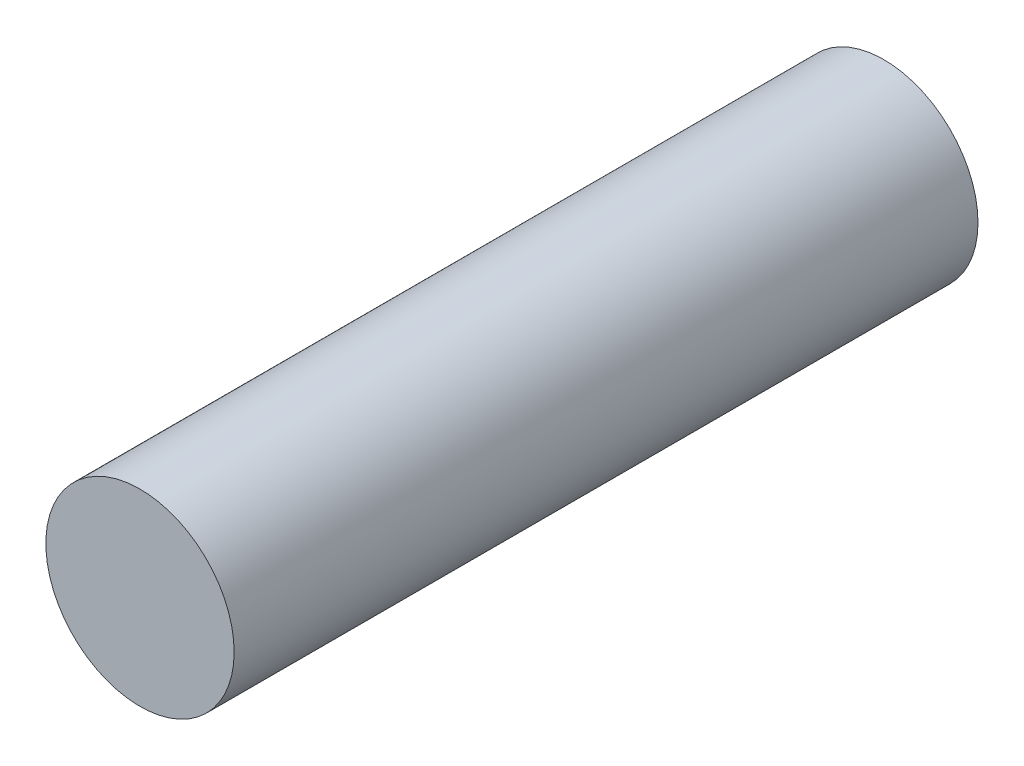
from build123d import *

# Parameters (mm, degrees)
SKETCH1_R           = 3.7970867
BOSS_EXTRUDE1_DEPTH = 30


with BuildPart() as part:
    # Sketch1 → Boss-Extrude1 (new body)
    with BuildSketch(Plane.XY):
        with Locations((-10.016557459, -10.016557459)):
            Circle(SKETCH1_R)
    extrude(amount=BOSS_EXTRUDE1_DEPTH)


solid = part.part
